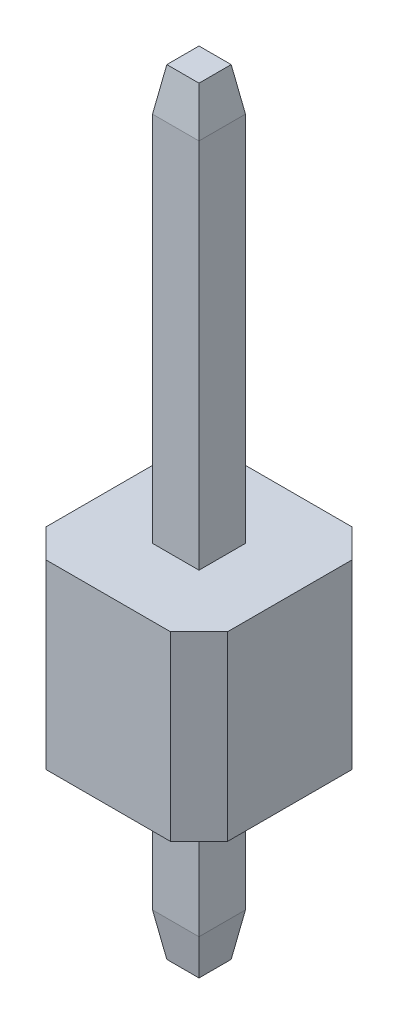
from build123d import *

# Parameters (mm, degrees)
SKETCH_1_W             = 2.54
SKETCH_1_H             = 2.54
EXTRUDE_1_DEPTH        = 2.54
CHAMFER_1_SIZE         = 0.4
SKETCH_2_W             = 0.65
SKETCH_2_H             = 0.65
EXTRUDE_2_DEPTH        = 5.8
EXTRUDE_START          = -2.54
SKETCH_2_2_W           = 0.65
SKETCH_2_2_H           = 0.65
EXTRUDE_3_DEPTH        = 2.5
CHAMFER_2_SIZE         = 0.6
CHAMFER_2_SIZE2        = 0.1
CHAMFER_2_PART_2_SIZE  = 0.6
CHAMFER_2_PART_2_SIZE2 = 0.1
CHAMFER_2_PART_3_SIZE  = 0.6
CHAMFER_2_PART_3_SIZE2 = 0.1
CHAMFER_2_PART_4_SIZE  = 0.6
CHAMFER_2_PART_4_SIZE2 = 0.1
CHAMFER_3_SIZE         = 0.1
CHAMFER_3_SIZE2        = 0.6


with BuildPart() as part:
    # Эскиз1 → Бобышка-Вытянуть1 (new body)
    with BuildSketch(Plane(origin=(0, 0, 0), x_dir=(1, 0, 0), z_dir=(0, 1, 0))):
        Rectangle(SKETCH_1_W, SKETCH_1_H)
    extrude(amount=EXTRUDE_1_DEPTH)

    # Фаска1
    chamfer_1_edges = [part.edges().sort_by_distance(p)[0] for p in [
        (-1.27, 1.27, -1.27),
        (1.27, 1.27, -1.27),
        (1.27, 1.27, 1.27),
        (-1.27, 1.27, 1.27),
    ]]
    chamfer(chamfer_1_edges, length=CHAMFER_1_SIZE)

    # Эскиз2 → Бобышка-Вытянуть2 (add)
    with BuildSketch(Plane(origin=(0, 2.54, 0), x_dir=(1, 0, 0), z_dir=(0, 1, 0))):
        Rectangle(SKETCH_2_W, SKETCH_2_H)
    extrude(amount=EXTRUDE_2_DEPTH)

    # Эскиз2<2> → Бобышка-Вытянуть3 (add)
    with BuildSketch(Plane(origin=(0, 2.54, 0), x_dir=(1, 0, 0), z_dir=(0, 1, 0)).offset(EXTRUDE_START)):
        Rectangle(SKETCH_2_2_W, SKETCH_2_2_H)
    extrude(amount=-EXTRUDE_3_DEPTH)

    # Фаска2
    chamfer_2_edges = [part.edges().sort_by_distance(p)[0] for p in [
        (-0.325, 8.34, 0),
    ]]
    chamfer_2_side = [part.faces().sort_by_distance(p)[0] for p in [
        (-0.325, 5.44, 0),
    ]]
    chamfer(chamfer_2_edges, length=CHAMFER_2_SIZE, length2=CHAMFER_2_SIZE2, reference=chamfer_2_side[0])

    # Фаска2 part 2
    chamfer_2_part_2_edges = [part.edges().sort_by_distance(p)[0] for p in [
        (0, 8.34, 0.325),
    ]]
    chamfer_2_part_2_side = [part.faces().sort_by_distance(p)[0] for p in [
        (0, 5.44, 0.325),
    ]]
    chamfer(chamfer_2_part_2_edges, length=CHAMFER_2_PART_2_SIZE, length2=CHAMFER_2_PART_2_SIZE2, reference=chamfer_2_part_2_side[0])

    # Фаска2 part 3
    chamfer_2_part_3_edges = [part.edges().sort_by_distance(p)[0] for p in [
        (0.325, 8.34, 0),
    ]]
    chamfer_2_part_3_side = [part.faces().sort_by_distance(p)[0] for p in [
        (0.325, 5.44, 0),
    ]]
    chamfer(chamfer_2_part_3_edges, length=CHAMFER_2_PART_3_SIZE, length2=CHAMFER_2_PART_3_SIZE2, reference=chamfer_2_part_3_side[0])

    # Фаска2 part 4
    chamfer_2_part_4_edges = [part.edges().sort_by_distance(p)[0] for p in [
        (0, 8.34, -0.325),
    ]]
    chamfer_2_part_4_side = [part.faces().sort_by_distance(p)[0] for p in [
        (0, 5.44, -0.325),
    ]]
    chamfer(chamfer_2_part_4_edges, length=CHAMFER_2_PART_4_SIZE, length2=CHAMFER_2_PART_4_SIZE2, reference=chamfer_2_part_4_side[0])

    # Фаска3
    chamfer_3_edges = [part.edges().sort_by_distance(p)[0] for p in [
        (-0.325, -2.5, 0),
        (0, -2.5, -0.325),
        (0.325, -2.5, 0),
        (0, -2.5, 0.325),
    ]]
    chamfer_3_side = [part.faces().sort_by_distance(p)[0] for p in [
        (0, -2.5, 0),
    ]]
    chamfer(chamfer_3_edges, length=CHAMFER_3_SIZE, length2=CHAMFER_3_SIZE2, reference=chamfer_3_side[0])


solid = part.part
